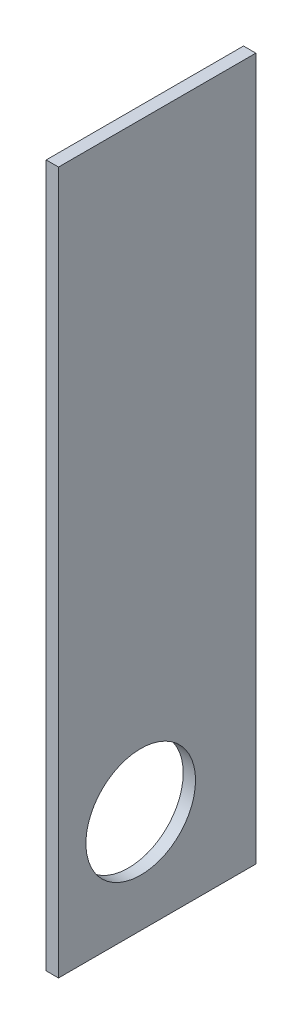
from build123d import *

# Parameters (mm, degrees)
SKETCH1_R           = 80
BOSS_EXTRUDE1_DEPTH = 18


with BuildPart() as part:
    # Sketch1 → Boss-Extrude1 (new body)
    with BuildSketch(Plane(origin=(0, 0, 0), x_dir=(0, 0, -1), z_dir=(1, 0, 0))):
        Polygon((20.392066811, -967.219556499), (-267.607933189, -967.219556499), (-267.607933189, -836.121901092), (-267.607933189, -676.121901092), (-267.607933189, 57.780443501), (20.392066811, 57.780443501), align=None)
        with Locations((-147.607933189, -817.219556499)):
            Circle(SKETCH1_R, mode=Mode.SUBTRACT)
    extrude(amount=BOSS_EXTRUDE1_DEPTH)


solid = part.part
